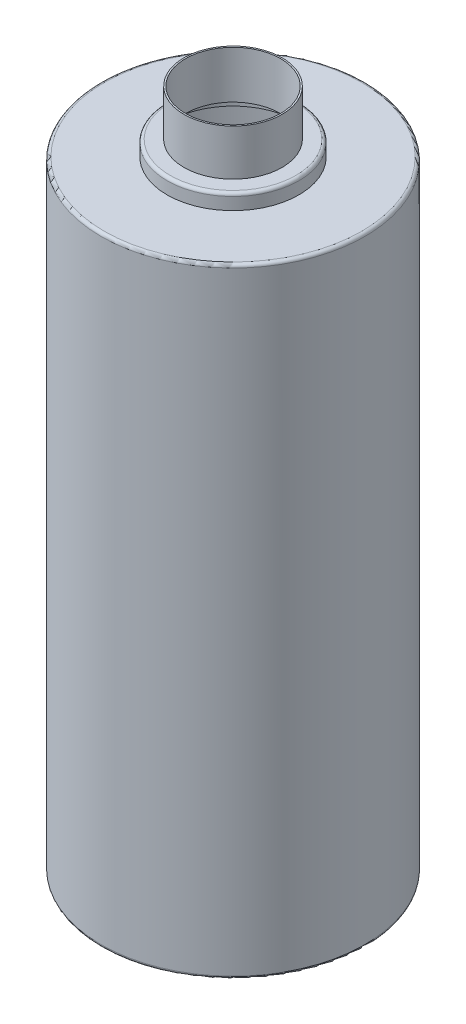
from build123d import *

# Parameters (mm, degrees)
FILLET_1_R = 1
SHELL_1_T  = -0.5


with BuildPart() as part:
    # 草图2 → 旋转1 (revolve)
    with BuildSketch(Plane.XY, mode=Mode.PRIVATE) as revolve_1_sk:
        Polygon((0, 111), (16, 111), (16, 96), (21.5, 96), (21.5, 91), (43, 91), (43, -111), (0, -111), align=None)
    revolve(revolve_1_sk.sketch.rotate(Axis((0, 36.939473279, 0), (0, -1, 0)), 90), axis=Axis((0, 36.939473279, 0), (0, -1, 0)))

    # 圆角1
    fillet_1_edges = [part.edges().sort_by_distance(p)[0] for p in [
        (0, -111, -43),
        (0, 91, -43),
        (0, 96, -21.5),
    ]]
    fillet(fillet_1_edges, radius=FILLET_1_R)

    # 抽壳1
    shell_1_openings = [part.faces().sort_by_distance(p)[0] for p in [
        (0, 111, 0),
    ]]
    offset(amount=SHELL_1_T, openings=shell_1_openings, kind=Kind.INTERSECTION)


solid = part.part
